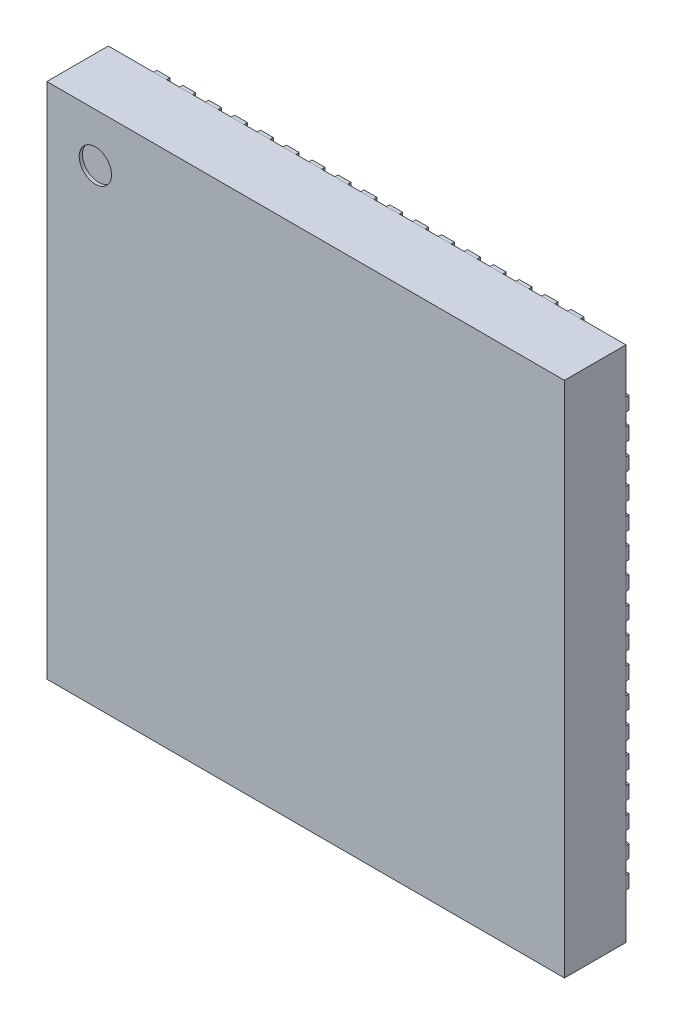
from build123d import *

# Parameters (mm, degrees)
SKETCH1_W           = 8
SKETCH1_H           = 8
BOSS_EXTRUDE1_DEPTH = 0.95
BOSS_EXTRUDE2_DEPTH = 0.05
SKETCH3_R           = 0.25
CUT_EXTRUDE1_DEPTH  = 0.05


with BuildPart() as part:
    # Sketch1 → Boss-Extrude1 (new body)
    with BuildSketch(Plane.XY):
        with Locations((4, 4)):
            Rectangle(SKETCH1_W, SKETCH1_H)
    extrude(amount=BOSS_EXTRUDE1_DEPTH)

    # Sketch3 → Cut-Extrude1 (cut)
    with BuildSketch(Plane.XY.offset(0.95)):
        with Locations((0.75, 7.25)):
            Circle(SKETCH3_R)
    extrude(amount=-CUT_EXTRUDE1_DEPTH, mode=Mode.SUBTRACT)


with BuildPart() as body_2:
    # Sketch2 → Boss-Extrude2 (new body)
    with BuildSketch(Plane(origin=(0, 0, 0), x_dir=(-1, 0, 0), z_dir=(0, 0, -1))):
        with BuildLine():
            Line((-3.7, 8), (-3.5, 8))
            Line((-3.5, 8), (-3.5, 7.61))
            ThreePointArc((-3.5, 7.61), (-3.6, 7.51), (-3.7, 7.61))
            Line((-3.7, 7.61), (-3.7, 8))
        make_face()
        with BuildLine():
            Line((-4.1, 8), (-3.9, 8))
            Line((-3.9, 8), (-3.9, 7.61))
            ThreePointArc((-3.9, 7.61), (-4, 7.51), (-4.1, 7.61))
            Line((-4.1, 7.61), (-4.1, 8))
        make_face()
        with BuildLine():
            Line((-3.3, 8), (-3.1, 8))
            Line((-3.1, 8), (-3.1, 7.61))
            ThreePointArc((-3.1, 7.61), (-3.2, 7.51), (-3.3, 7.61))
            Line((-3.3, 7.61), (-3.3, 8))
        make_face()
        with BuildLine():
            Line((-2.9, 8), (-2.7, 8))
            Line((-2.7, 8), (-2.7, 7.61))
            ThreePointArc((-2.7, 7.61), (-2.8, 7.51), (-2.9, 7.61))
            Line((-2.9, 7.61), (-2.9, 8))
        make_face()
        with BuildLine():
            Line((-2.5, 8), (-2.3, 8))
            Line((-2.3, 8), (-2.3, 7.61))
            ThreePointArc((-2.3, 7.61), (-2.4, 7.51), (-2.5, 7.61))
            Line((-2.5, 7.61), (-2.5, 8))
        make_face()
        with BuildLine():
            Line((-2.1, 8), (-1.9, 8))
            Line((-1.9, 8), (-1.9, 7.61))
            ThreePointArc((-1.9, 7.61), (-2, 7.51), (-2.1, 7.61))
            Line((-2.1, 7.61), (-2.1, 8))
        make_face()
        with BuildLine():
            Line((-1.7, 8), (-1.5, 8))
            Line((-1.5, 8), (-1.5, 7.61))
            ThreePointArc((-1.5, 7.61), (-1.6, 7.51), (-1.7, 7.61))
            Line((-1.7, 7.61), (-1.7, 8))
        make_face()
        with BuildLine():
            Line((-4.5, 8), (-4.3, 8))
            Line((-4.3, 8), (-4.3, 7.61))
            ThreePointArc((-4.3, 7.61), (-4.4, 7.51), (-4.5, 7.61))
            Line((-4.5, 7.61), (-4.5, 8))
        make_face()
        with BuildLine():
            Line((-4.9, 8), (-4.7, 8))
            Line((-4.7, 8), (-4.7, 7.61))
            ThreePointArc((-4.7, 7.61), (-4.8, 7.51), (-4.9, 7.61))
            Line((-4.9, 7.61), (-4.9, 8))
        make_face()
        with BuildLine():
            Line((-5.3, 8), (-5.1, 8))
            Line((-5.1, 8), (-5.1, 7.61))
            ThreePointArc((-5.1, 7.61), (-5.2, 7.51), (-5.3, 7.61))
            Line((-5.3, 7.61), (-5.3, 8))
        make_face()
        with BuildLine():
            Line((-5.7, 8), (-5.5, 8))
            Line((-5.5, 8), (-5.5, 7.61))
            ThreePointArc((-5.5, 7.61), (-5.6, 7.51), (-5.7, 7.61))
            Line((-5.7, 7.61), (-5.7, 8))
        make_face()
        with BuildLine():
            Line((-6.1, 8), (-5.9, 8))
            Line((-5.9, 8), (-5.9, 7.61))
            ThreePointArc((-5.9, 7.61), (-6, 7.51), (-6.1, 7.61))
            Line((-6.1, 7.61), (-6.1, 8))
        make_face()
        with BuildLine():
            Line((-6.5, 8), (-6.3, 8))
            Line((-6.3, 8), (-6.3, 7.61))
            ThreePointArc((-6.3, 7.61), (-6.4, 7.51), (-6.5, 7.61))
            Line((-6.5, 7.61), (-6.5, 8))
        make_face()
        with BuildLine():
            Line((-6.9, 8), (-6.7, 8))
            Line((-6.7, 8), (-6.7, 7.61))
            ThreePointArc((-6.7, 7.61), (-6.8, 7.51), (-6.9, 7.61))
            Line((-6.9, 7.61), (-6.9, 8))
        make_face()
        with BuildLine():
            Line((-7.3, 8), (-7.1, 8))
            Line((-7.1, 8), (-7.1, 7.61))
            ThreePointArc((-7.1, 7.61), (-7.2, 7.51), (-7.3, 7.61))
            Line((-7.3, 7.61), (-7.3, 8))
        make_face()
        with BuildLine():
            Line((-1.3, 8), (-1.1, 8))
            Line((-1.1, 8), (-1.1, 7.61))
            ThreePointArc((-1.1, 7.61), (-1.2, 7.51), (-1.3, 7.61))
            Line((-1.3, 7.61), (-1.3, 8))
        make_face()
        with BuildLine():
            Line((-0.9, 8), (-0.7, 8))
            Line((-0.7, 8), (-0.7, 7.61))
            ThreePointArc((-0.7, 7.61), (-0.8, 7.51), (-0.9, 7.61))
            Line((-0.9, 7.61), (-0.9, 8))
        make_face()
        with BuildLine():
            Line((0, 3.7), (0, 3.5))
            Line((0, 3.5), (-0.39, 3.5))
            ThreePointArc((-0.39, 3.5), (-0.49, 3.6), (-0.39, 3.7))
            Line((-0.39, 3.7), (0, 3.7))
        make_face()
        with BuildLine():
            Line((0, 4.1), (0, 3.9))
            Line((0, 3.9), (-0.39, 3.9))
            ThreePointArc((-0.39, 3.9), (-0.49, 4), (-0.39, 4.1))
            Line((-0.39, 4.1), (0, 4.1))
        make_face()
        with BuildLine():
            Line((0, 3.3), (0, 3.1))
            Line((0, 3.1), (-0.39, 3.1))
            ThreePointArc((-0.39, 3.1), (-0.49, 3.2), (-0.39, 3.3))
            Line((-0.39, 3.3), (0, 3.3))
        make_face()
        with BuildLine():
            Line((0, 2.9), (0, 2.7))
            Line((0, 2.7), (-0.39, 2.7))
            ThreePointArc((-0.39, 2.7), (-0.49, 2.8), (-0.39, 2.9))
            Line((-0.39, 2.9), (0, 2.9))
        make_face()
        with BuildLine():
            Line((0, 2.5), (0, 2.3))
            Line((0, 2.3), (-0.39, 2.3))
            ThreePointArc((-0.39, 2.3), (-0.49, 2.4), (-0.39, 2.5))
            Line((-0.39, 2.5), (0, 2.5))
        make_face()
        with BuildLine():
            Line((0, 2.1), (0, 1.9))
            Line((0, 1.9), (-0.39, 1.9))
            ThreePointArc((-0.39, 1.9), (-0.49, 2), (-0.39, 2.1))
            Line((-0.39, 2.1), (0, 2.1))
        make_face()
        with BuildLine():
            Line((0, 1.7), (0, 1.5))
            Line((0, 1.5), (-0.39, 1.5))
            ThreePointArc((-0.39, 1.5), (-0.49, 1.6), (-0.39, 1.7))
            Line((-0.39, 1.7), (0, 1.7))
        make_face()
        with BuildLine():
            Line((0, 4.5), (0, 4.3))
            Line((0, 4.3), (-0.39, 4.3))
            ThreePointArc((-0.39, 4.3), (-0.49, 4.4), (-0.39, 4.5))
            Line((-0.39, 4.5), (0, 4.5))
        make_face()
        with BuildLine():
            Line((0, 4.9), (0, 4.7))
            Line((0, 4.7), (-0.39, 4.7))
            ThreePointArc((-0.39, 4.7), (-0.49, 4.8), (-0.39, 4.9))
            Line((-0.39, 4.9), (0, 4.9))
        make_face()
        with BuildLine():
            Line((0, 5.3), (0, 5.1))
            Line((0, 5.1), (-0.39, 5.1))
            ThreePointArc((-0.39, 5.1), (-0.49, 5.2), (-0.39, 5.3))
            Line((-0.39, 5.3), (0, 5.3))
        make_face()
        with BuildLine():
            Line((0, 5.7), (0, 5.5))
            Line((0, 5.5), (-0.39, 5.5))
            ThreePointArc((-0.39, 5.5), (-0.49, 5.6), (-0.39, 5.7))
            Line((-0.39, 5.7), (0, 5.7))
        make_face()
        with BuildLine():
            Line((0, 6.1), (0, 5.9))
            Line((0, 5.9), (-0.39, 5.9))
            ThreePointArc((-0.39, 5.9), (-0.49, 6), (-0.39, 6.1))
            Line((-0.39, 6.1), (0, 6.1))
        make_face()
        with BuildLine():
            Line((0, 6.5), (0, 6.3))
            Line((0, 6.3), (-0.39, 6.3))
            ThreePointArc((-0.39, 6.3), (-0.49, 6.4), (-0.39, 6.5))
            Line((-0.39, 6.5), (0, 6.5))
        make_face()
        with BuildLine():
            Line((0, 6.9), (0, 6.7))
            Line((0, 6.7), (-0.39, 6.7))
            ThreePointArc((-0.39, 6.7), (-0.49, 6.8), (-0.39, 6.9))
            Line((-0.39, 6.9), (0, 6.9))
        make_face()
        with BuildLine():
            Line((0, 7.3), (0, 7.1))
            Line((0, 7.1), (-0.39, 7.1))
            ThreePointArc((-0.39, 7.1), (-0.49, 7.2), (-0.39, 7.3))
            Line((-0.39, 7.3), (0, 7.3))
        make_face()
        with BuildLine():
            Line((0, 1.3), (0, 1.1))
            Line((0, 1.1), (-0.39, 1.1))
            ThreePointArc((-0.39, 1.1), (-0.49, 1.2), (-0.39, 1.3))
            Line((-0.39, 1.3), (0, 1.3))
        make_face()
        with BuildLine():
            Line((0, 0.9), (0, 0.7))
            Line((0, 0.7), (-0.39, 0.7))
            ThreePointArc((-0.39, 0.7), (-0.49, 0.8), (-0.39, 0.9))
            Line((-0.39, 0.9), (0, 0.9))
        make_face()
        with BuildLine():
            Line((-4.3, 0), (-4.5, 0))
            Line((-4.5, 0), (-4.5, 0.39))
            ThreePointArc((-4.5, 0.39), (-4.4, 0.49), (-4.3, 0.39))
            Line((-4.3, 0.39), (-4.3, 0))
        make_face()
        with BuildLine():
            Line((-3.9, 0), (-4.1, 0))
            Line((-4.1, 0), (-4.1, 0.39))
            ThreePointArc((-4.1, 0.39), (-4, 0.49), (-3.9, 0.39))
            Line((-3.9, 0.39), (-3.9, 0))
        make_face()
        with BuildLine():
            Line((-4.7, 0), (-4.9, 0))
            Line((-4.9, 0), (-4.9, 0.39))
            ThreePointArc((-4.9, 0.39), (-4.8, 0.49), (-4.7, 0.39))
            Line((-4.7, 0.39), (-4.7, 0))
        make_face()
        with BuildLine():
            Line((-5.1, 0), (-5.3, 0))
            Line((-5.3, 0), (-5.3, 0.39))
            ThreePointArc((-5.3, 0.39), (-5.2, 0.49), (-5.1, 0.39))
            Line((-5.1, 0.39), (-5.1, 0))
        make_face()
        with BuildLine():
            Line((-5.5, 0), (-5.7, 0))
            Line((-5.7, 0), (-5.7, 0.39))
            ThreePointArc((-5.7, 0.39), (-5.6, 0.49), (-5.5, 0.39))
            Line((-5.5, 0.39), (-5.5, 0))
        make_face()
        with BuildLine():
            Line((-5.9, 0), (-6.1, 0))
            Line((-6.1, 0), (-6.1, 0.39))
            ThreePointArc((-6.1, 0.39), (-6, 0.49), (-5.9, 0.39))
            Line((-5.9, 0.39), (-5.9, 0))
        make_face()
        with BuildLine():
            Line((-6.3, 0), (-6.5, 0))
            Line((-6.5, 0), (-6.5, 0.39))
            ThreePointArc((-6.5, 0.39), (-6.4, 0.49), (-6.3, 0.39))
            Line((-6.3, 0.39), (-6.3, 0))
        make_face()
        with BuildLine():
            Line((-3.5, 0), (-3.7, 0))
            Line((-3.7, 0), (-3.7, 0.39))
            ThreePointArc((-3.7, 0.39), (-3.6, 0.49), (-3.5, 0.39))
            Line((-3.5, 0.39), (-3.5, 0))
        make_face()
        with BuildLine():
            Line((-3.1, 0), (-3.3, 0))
            Line((-3.3, 0), (-3.3, 0.39))
            ThreePointArc((-3.3, 0.39), (-3.2, 0.49), (-3.1, 0.39))
            Line((-3.1, 0.39), (-3.1, 0))
        make_face()
        with BuildLine():
            Line((-2.7, 0), (-2.9, 0))
            Line((-2.9, 0), (-2.9, 0.39))
            ThreePointArc((-2.9, 0.39), (-2.8, 0.49), (-2.7, 0.39))
            Line((-2.7, 0.39), (-2.7, 0))
        make_face()
        with BuildLine():
            Line((-2.3, 0), (-2.5, 0))
            Line((-2.5, 0), (-2.5, 0.39))
            ThreePointArc((-2.5, 0.39), (-2.4, 0.49), (-2.3, 0.39))
            Line((-2.3, 0.39), (-2.3, 0))
        make_face()
        with BuildLine():
            Line((-1.9, 0), (-2.1, 0))
            Line((-2.1, 0), (-2.1, 0.39))
            ThreePointArc((-2.1, 0.39), (-2, 0.49), (-1.9, 0.39))
            Line((-1.9, 0.39), (-1.9, 0))
        make_face()
        with BuildLine():
            Line((-1.5, 0), (-1.7, 0))
            Line((-1.7, 0), (-1.7, 0.39))
            ThreePointArc((-1.7, 0.39), (-1.6, 0.49), (-1.5, 0.39))
            Line((-1.5, 0.39), (-1.5, 0))
        make_face()
        with BuildLine():
            Line((-1.1, 0), (-1.3, 0))
            Line((-1.3, 0), (-1.3, 0.39))
            ThreePointArc((-1.3, 0.39), (-1.2, 0.49), (-1.1, 0.39))
            Line((-1.1, 0.39), (-1.1, 0))
        make_face()
        with BuildLine():
            Line((-0.7, 0), (-0.9, 0))
            Line((-0.9, 0), (-0.9, 0.39))
            ThreePointArc((-0.9, 0.39), (-0.8, 0.49), (-0.7, 0.39))
            Line((-0.7, 0.39), (-0.7, 0))
        make_face()
        with BuildLine():
            Line((-6.7, 0), (-6.9, 0))
            Line((-6.9, 0), (-6.9, 0.39))
            ThreePointArc((-6.9, 0.39), (-6.8, 0.49), (-6.7, 0.39))
            Line((-6.7, 0.39), (-6.7, 0))
        make_face()
        with BuildLine():
            Line((-7.1, 0), (-7.3, 0))
            Line((-7.3, 0), (-7.3, 0.39))
            ThreePointArc((-7.3, 0.39), (-7.2, 0.49), (-7.1, 0.39))
            Line((-7.1, 0.39), (-7.1, 0))
        make_face()
        with BuildLine():
            Line((-8, 4.3), (-8, 4.5))
            Line((-8, 4.5), (-7.61, 4.5))
            ThreePointArc((-7.61, 4.5), (-7.51, 4.4), (-7.61, 4.3))
            Line((-7.61, 4.3), (-8, 4.3))
        make_face()
        with BuildLine():
            Line((-8, 3.9), (-8, 4.1))
            Line((-8, 4.1), (-7.61, 4.1))
            ThreePointArc((-7.61, 4.1), (-7.51, 4), (-7.61, 3.9))
            Line((-7.61, 3.9), (-8, 3.9))
        make_face()
        with BuildLine():
            Line((-8, 4.7), (-8, 4.9))
            Line((-8, 4.9), (-7.61, 4.9))
            ThreePointArc((-7.61, 4.9), (-7.51, 4.8), (-7.61, 4.7))
            Line((-7.61, 4.7), (-8, 4.7))
        make_face()
        with BuildLine():
            Line((-8, 5.1), (-8, 5.3))
            Line((-8, 5.3), (-7.61, 5.3))
            ThreePointArc((-7.61, 5.3), (-7.51, 5.2), (-7.61, 5.1))
            Line((-7.61, 5.1), (-8, 5.1))
        make_face()
        with BuildLine():
            Line((-8, 5.5), (-8, 5.7))
            Line((-8, 5.7), (-7.61, 5.7))
            ThreePointArc((-7.61, 5.7), (-7.51, 5.6), (-7.61, 5.5))
            Line((-7.61, 5.5), (-8, 5.5))
        make_face()
        with BuildLine():
            Line((-8, 5.9), (-8, 6.1))
            Line((-8, 6.1), (-7.61, 6.1))
            ThreePointArc((-7.61, 6.1), (-7.51, 6), (-7.61, 5.9))
            Line((-7.61, 5.9), (-8, 5.9))
        make_face()
        with BuildLine():
            Line((-8, 6.3), (-8, 6.5))
            Line((-8, 6.5), (-7.61, 6.5))
            ThreePointArc((-7.61, 6.5), (-7.51, 6.4), (-7.61, 6.3))
            Line((-7.61, 6.3), (-8, 6.3))
        make_face()
        with BuildLine():
            Line((-1.15, 5.7), (-1.15, 1.15))
            Line((-1.15, 1.15), (-6.85, 1.15))
            Line((-6.85, 1.15), (-6.85, 6.85))
            Line((-6.85, 6.85), (-1.15, 6.85))
            Line((-1.15, 6.85), (-1.15, 6.3))
            ThreePointArc((-1.15, 6.3), (-1.45, 6), (-1.15, 5.7))
        make_face()
        with BuildLine():
            Line((-8, 3.5), (-8, 3.7))
            Line((-8, 3.7), (-7.61, 3.7))
            ThreePointArc((-7.61, 3.7), (-7.51, 3.6), (-7.61, 3.5))
            Line((-7.61, 3.5), (-8, 3.5))
        make_face()
        with BuildLine():
            Line((-8, 3.1), (-8, 3.3))
            Line((-8, 3.3), (-7.61, 3.3))
            ThreePointArc((-7.61, 3.3), (-7.51, 3.2), (-7.61, 3.1))
            Line((-7.61, 3.1), (-8, 3.1))
        make_face()
        with BuildLine():
            Line((-8, 2.7), (-8, 2.9))
            Line((-8, 2.9), (-7.61, 2.9))
            ThreePointArc((-7.61, 2.9), (-7.51, 2.8), (-7.61, 2.7))
            Line((-7.61, 2.7), (-8, 2.7))
        make_face()
        with BuildLine():
            Line((-8, 2.3), (-8, 2.5))
            Line((-8, 2.5), (-7.61, 2.5))
            ThreePointArc((-7.61, 2.5), (-7.51, 2.4), (-7.61, 2.3))
            Line((-7.61, 2.3), (-8, 2.3))
        make_face()
        with BuildLine():
            Line((-8, 1.9), (-8, 2.1))
            Line((-8, 2.1), (-7.61, 2.1))
            ThreePointArc((-7.61, 2.1), (-7.51, 2), (-7.61, 1.9))
            Line((-7.61, 1.9), (-8, 1.9))
        make_face()
        with BuildLine():
            Line((-8, 1.5), (-8, 1.7))
            Line((-8, 1.7), (-7.61, 1.7))
            ThreePointArc((-7.61, 1.7), (-7.51, 1.6), (-7.61, 1.5))
            Line((-7.61, 1.5), (-8, 1.5))
        make_face()
        with BuildLine():
            Line((-8, 1.1), (-8, 1.3))
            Line((-8, 1.3), (-7.61, 1.3))
            ThreePointArc((-7.61, 1.3), (-7.51, 1.2), (-7.61, 1.1))
            Line((-7.61, 1.1), (-8, 1.1))
        make_face()
        with BuildLine():
            Line((-8, 0.7), (-8, 0.9))
            Line((-8, 0.9), (-7.61, 0.9))
            ThreePointArc((-7.61, 0.9), (-7.51, 0.8), (-7.61, 0.7))
            Line((-7.61, 0.7), (-8, 0.7))
        make_face()
        with BuildLine():
            Line((-8, 6.7), (-8, 6.9))
            Line((-8, 6.9), (-7.61, 6.9))
            ThreePointArc((-7.61, 6.9), (-7.51, 6.8), (-7.61, 6.7))
            Line((-7.61, 6.7), (-8, 6.7))
        make_face()
        with BuildLine():
            Line((-8, 7.1), (-8, 7.3))
            Line((-8, 7.3), (-7.61, 7.3))
            ThreePointArc((-7.61, 7.3), (-7.51, 7.2), (-7.61, 7.1))
            Line((-7.61, 7.1), (-8, 7.1))
        make_face()
    extrude(amount=BOSS_EXTRUDE2_DEPTH)


solid = Compound([part.part, body_2.part])
